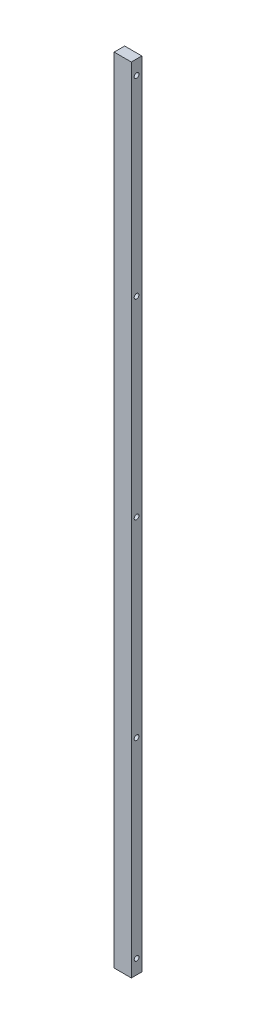
from build123d import *

# Parameters (mm, degrees)
SKETCH_1_W             = 18
SKETCH_1_H             = 830
EXTRUDE_1_DEPTH        = 5.5
HOLE_WIZARD_M6_1_D     = 5
HOLE_WIZARD_M6_1_DEPTH = 15
HOLE_WIZARD_M6_1_TIP   = 1.502151548


with BuildPart() as part:
    # 草图1 → 凸台-拉伸1 (new body, symmetric)
    with BuildSketch(Plane.XY):
        Rectangle(SKETCH_1_W, SKETCH_1_H)
    extrude(amount=EXTRUDE_1_DEPTH, both=True)

    # M6 螺纹孔1
    with Locations(Plane(origin=(9, -400, 0), x_dir=(0, 0, 1), z_dir=(1, 0, 0))):
        with Locations((0, 0), (0, -200), (0, -400), (0, -600), (0, -800)):
            Hole(HOLE_WIZARD_M6_1_D / 2, depth=HOLE_WIZARD_M6_1_DEPTH)
            with Locations((0, 0, -(HOLE_WIZARD_M6_1_DEPTH + HOLE_WIZARD_M6_1_TIP / 2))):  # 118° drill point
                Cone(0, HOLE_WIZARD_M6_1_D / 2, HOLE_WIZARD_M6_1_TIP, mode=Mode.SUBTRACT)


solid = part.part
